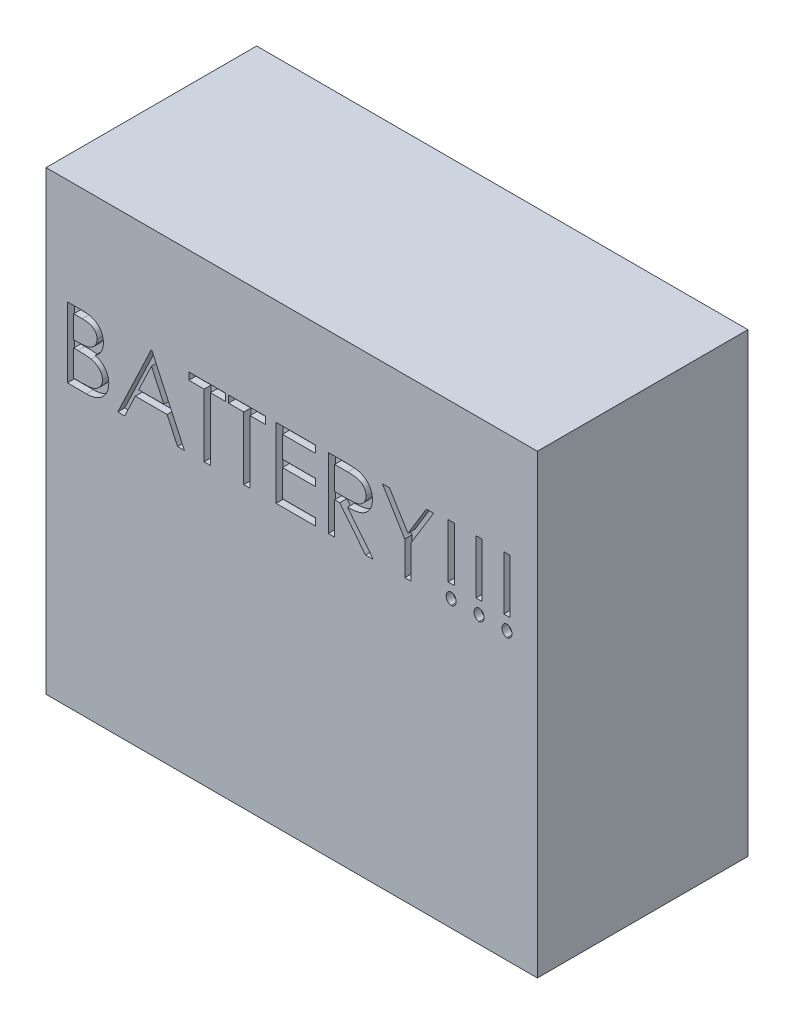
from build123d import *

# Parameters (mm, degrees)
SKETCH1_W           = 177.8
SKETCH1_H           = 76.2
BOSS_EXTRUDE1_DEPTH = 82.55
SKETCH2_W           = 2.279487179
SKETCH2_H           = 19.538461538
SKETCH2_W_2         = 2.27948718
CUT_EXTRUDE1_DEPTH  = 2.54


with BuildPart() as part:
    # Sketch1 → Boss-Extrude1 (new body, symmetric)
    with BuildSketch(Plane(origin=(0, 0, 0), x_dir=(1, 0, 0), z_dir=(0, 1, 0))):
        Rectangle(SKETCH1_W, SKETCH1_H)
    extrude(amount=BOSS_EXTRUDE1_DEPTH, both=True)

    # Sketch2 → Cut-Extrude1 (cut)
    with BuildSketch(Plane.XY.offset(38.1)):
        with BuildLine():
            Line((-81.188057104, 44.331904779), (-76.232207745, 44.331904779))
            add(Edge.make_bspline(
                [(-76.232207745, 44.331904779), (-75.989612503, 44.330629333), (-75.519402548, 44.328157202), (-74.835638599, 44.289816765), (-74.195204373, 44.237538703), (-73.597914139, 44.154588888), (-73.044043899, 44.054499991), (-72.531924474, 43.933292526), (-72.063184367, 43.787956529), (-71.503566223, 43.556843517), (-70.865513427, 43.213412524), (-70.174645091, 42.705930937), (-69.583882897, 42.085209633), (-69.074530766, 41.385021219), (-68.66957407, 40.614778761), (-68.376608312, 39.792840649), (-68.191131159, 38.929808579), (-68.172056237, 38.337312373), (-68.162416078, 38.03787433)],
                knots=[0, 0, 0, 0, 0.000727675, 0.001410416, 0.00205396, 0.002654813, 0.003218679, 0.003741942, 0.004232757, 0.004689132, 0.005556522, 0.006400141, 0.007249358, 0.008116494, 0.00899047, 0.0098499, 0.010728043, 0.011625303, 0.011625303, 0.011625303, 0.011625303], degree=3))
            add(Edge.make_bspline(
                [(-68.162416078, 38.03787433), (-68.17034972, 37.757367212), (-68.185940076, 37.206144271), (-68.335021815, 36.39991845), (-68.56841638, 35.632466747), (-68.89284876, 34.906590007), (-69.314503247, 34.238688929), (-69.814217902, 33.623375627), (-70.417118126, 33.086702242), (-70.86882621, 32.786670892), (-71.09827345, 32.634268561)],
                knots=[0, 0, 0, 0, 0.000840791, 0.001652234, 0.002450537, 0.003243047, 0.004029408, 0.00481379, 0.005613681, 0.006439435, 0.006439435, 0.006439435, 0.006439435], degree=3))
            add(Edge.make_bspline(
                [(-71.09827345, 32.634268561), (-70.809726347, 32.523488283), (-70.25766426, 32.311538169), (-69.497942913, 31.93681223), (-68.843386037, 31.529235772), (-68.288961035, 31.084141774), (-67.814796339, 30.60438069), (-67.400754992, 30.082917861), (-67.047467305, 29.512950875), (-66.74475066, 28.900422361), (-66.508539688, 28.251586848), (-66.331640267, 27.572530359), (-66.230276494, 26.865687872), (-66.215851897, 26.384645405), (-66.208569924, 26.141800612)],
                knots=[0, 0, 0, 0, 0.000926894, 0.001773378, 0.002537091, 0.003235576, 0.003901189, 0.00455677, 0.00522879, 0.005909176, 0.006602975, 0.007296532, 0.008011067, 0.008739542, 0.008739542, 0.008739542, 0.008739542], degree=3))
            add(Edge.make_bspline(
                [(-66.208569924, 26.141800612), (-66.215659035, 25.89384674), (-66.22960706, 25.405990551), (-66.332513141, 24.689310431), (-66.50675066, 24.004417962), (-66.746752694, 23.346883207), (-67.059987777, 22.717978231), (-67.441190718, 22.116990544), (-67.895716923, 21.549958545), (-68.404173172, 21.010581394), (-68.979389885, 20.525602595), (-69.599989935, 20.093688609), (-70.273788942, 19.738480044), (-70.989720556, 19.440095202), (-71.755815878, 19.212168676), (-72.5686348, 19.052710569), (-73.427476305, 18.9452683), (-74.01682707, 18.93643487), (-74.319066719, 18.931904779)],
                knots=[0, 0, 0, 0, 0.000743722, 0.001463294, 0.00216671, 0.002860509, 0.003559087, 0.004270499, 0.004991239, 0.005736213, 0.006490649, 0.007244313, 0.008000052, 0.008771102, 0.009567929, 0.010393165, 0.011254009, 0.012160212, 0.012160212, 0.012160212, 0.012160212], degree=3))
            Line((-74.319066719, 18.931904779), (-81.188057104, 18.931904779))
            Line((-81.188057104, 18.931904779), (-81.188057104, 44.331904779))
        make_face()
        with BuildLine():
            Line((-78.908569924, 41.726776574), (-78.908569924, 33.585750933))
            Line((-78.908569924, 33.585750933), (-77.377039475, 33.585750933))
            add(Edge.make_bspline(
                [(-77.377039475, 33.585750933), (-77.15316536, 33.588653231), (-76.720594948, 33.594261063), (-76.094159127, 33.610324873), (-75.512680423, 33.655304959), (-74.977162549, 33.700272118), (-74.488448813, 33.77338484), (-74.047621932, 33.860413389), (-73.647763543, 33.952455043), (-73.186647984, 34.108987891), (-72.663604301, 34.340328734), (-72.106015488, 34.699352916), (-71.614456766, 35.126975365), (-71.199368603, 35.620395487), (-70.859651074, 36.163710093), (-70.623694399, 36.748250311), (-70.463694108, 37.359447841), (-70.44924128, 37.779043161), (-70.441903257, 37.992081061)],
                knots=[0, 0, 0, 0, 0.000671712, 0.001297884, 0.001879358, 0.002421096, 0.00290969, 0.00336073, 0.00376921, 0.004139283, 0.004820201, 0.005479326, 0.006121199, 0.006767473, 0.007407143, 0.008034555, 0.008652821, 0.009290485, 0.009290485, 0.009290485, 0.009290485], degree=3))
            add(Edge.make_bspline(
                [(-70.441903257, 37.992081061), (-70.445721822, 38.13305666), (-70.453212354, 38.409595692), (-70.514559179, 38.812725291), (-70.618826719, 39.191865666), (-70.752752161, 39.552212638), (-70.939904359, 39.882498637), (-71.16025635, 40.194143543), (-71.426489645, 40.476534346), (-71.729528429, 40.74047299), (-72.077933863, 40.974476135), (-72.471498095, 41.179423388), (-72.915545809, 41.344456453), (-73.402593385, 41.488990817), (-73.940137848, 41.590505863), (-74.521976036, 41.675076162), (-75.152873711, 41.718130918), (-75.589355312, 41.723830409), (-75.81498018, 41.726776574)],
                knots=[0, 0, 0, 0, 0.000422806, 0.00082938, 0.001219412, 0.001601158, 0.001979224, 0.002354817, 0.002743652, 0.003140462, 0.003558186, 0.003999683, 0.004468372, 0.004977186, 0.005522021, 0.006107755, 0.006740344, 0.007417239, 0.007417239, 0.007417239, 0.007417239], degree=3))
            Line((-75.81498018, 41.726776574), (-78.908569924, 41.726776574))
        make_face(mode=Mode.SUBTRACT)
        with BuildLine():
            Line((-78.908569924, 30.980622728), (-78.908569924, 21.537032984))
            Line((-78.908569924, 21.537032984), (-75.66233595, 21.537032984))
            add(Edge.make_bspline(
                [(-75.66233595, 21.537032984), (-75.42997003, 21.539817894), (-74.982115354, 21.54518544), (-74.335494998, 21.562708208), (-73.736177616, 21.602566437), (-73.186898003, 21.665310603), (-72.681725003, 21.733371348), (-72.226718816, 21.824893216), (-71.818191069, 21.929751386), (-71.344486093, 22.091833665), (-70.811060633, 22.343630911), (-70.236216132, 22.723282726), (-69.725123006, 23.175571873), (-69.291107696, 23.699036222), (-68.935413437, 24.268223566), (-68.676656705, 24.871621248), (-68.517065917, 25.499259076), (-68.497746174, 25.927188933), (-68.488057104, 26.141800612)],
                knots=[0, 0, 0, 0, 0.00069715, 0.001343664, 0.001940366, 0.002498325, 0.003002025, 0.003469026, 0.003889868, 0.004266391, 0.004969696, 0.005652721, 0.006326684, 0.007009424, 0.007685764, 0.008333159, 0.008972405, 0.009615526, 0.009615526, 0.009615526, 0.009615526], degree=3))
            add(Edge.make_bspline(
                [(-68.488057104, 26.141800612), (-68.490060832, 26.276009426), (-68.494035969, 26.542262254), (-68.553984432, 26.933537056), (-68.641170801, 27.31254768), (-68.753884636, 27.680323282), (-68.91803734, 28.030214642), (-69.109673409, 28.369141788), (-69.334364724, 28.697552753), (-69.684479528, 29.11275025), (-70.193727644, 29.591119429), (-70.917313957, 30.059477303), (-71.740072919, 30.437195674), (-72.336809582, 30.597574731), (-72.645068322, 30.680422407)],
                knots=[0, 0, 0, 0, 0.000402253, 0.000798017, 0.001184348, 0.001568932, 0.001949183, 0.002341102, 0.002736277, 0.003140841, 0.003968849, 0.00482123, 0.005716063, 0.006672255, 0.006672255, 0.006672255, 0.006672255], degree=3))
            add(Edge.make_bspline(
                [(-72.645068322, 30.680422407), (-72.768650903, 30.705496445), (-73.03660343, 30.759862131), (-73.473538442, 30.817249464), (-73.972364462, 30.86837647), (-74.534233343, 30.906194586), (-75.159855961, 30.945285502), (-75.850568457, 30.960487918), (-76.603550112, 30.978625406), (-77.126009043, 30.979939923), (-77.397392039, 30.980622728)],
                knots=[0, 0, 0, 0, 0.000378203, 0.000820023, 0.00132125, 0.001882424, 0.002509278, 0.003201564, 0.003954764, 0.004768882, 0.004768882, 0.004768882, 0.004768882], degree=3))
            Line((-77.397392039, 30.980622728), (-78.908569924, 30.980622728))
        make_face(mode=Mode.SUBTRACT)
        Polygon((-50.577800693, 44.331904779), (-38.85472377, 18.931904779), (-41.33264845, 18.931904779), (-45.087696527, 27.07293042), (-56.602159668, 27.07293042), (-60.464058706, 18.931904779), (-62.952159668, 18.931904779), (-50.903441719, 44.331904779), align=None)
        Polygon((-50.766061911, 39.381143561), (-55.365741398, 29.678058625), (-46.288497809, 29.678058625), align=None, mode=Mode.SUBTRACT)
        Polygon((-37.226518642, 41.726776574), (-37.226518642, 44.331904779), (-23.875236591, 44.331904779), (-23.875236591, 41.726776574), (-29.411134027, 41.726776574), (-29.411134027, 18.931904779), (-31.690621206, 18.931904779), (-31.690621206, 41.726776574), align=None)
        Polygon((-22.898313514, 41.726776574), (-22.898313514, 44.331904779), (-9.547031463, 44.331904779), (-9.547031463, 41.726776574), (-15.082928898, 41.726776574), (-15.082928898, 18.931904779), (-17.362416078, 18.931904779), (-17.362416078, 41.726776574), align=None)
        Polygon((-5.639339155, 44.331904779), (8.688865973, 44.331904779), (8.688865973, 41.726776574), (-3.359851975, 41.726776574), (-3.359851975, 33.911391959), (8.688865973, 33.911391959), (8.688865973, 31.306263753), (-3.359851975, 31.306263753), (-3.359851975, 21.537032984), (8.688865973, 21.537032984), (8.688865973, 18.931904779), (-5.639339155, 18.931904779), align=None)
        with BuildLine():
            Line((13.247840332, 44.331904779), (18.330893217, 44.331904779))
            add(Edge.make_bspline(
                [(18.330893217, 44.331904779), (18.670100264, 44.330775669), (19.321415369, 44.328607654), (20.25448996, 44.316518974), (21.102320892, 44.281870793), (21.864464869, 44.252054216), (22.540907908, 44.197684127), (23.133724246, 44.145718288), (23.640183537, 44.077692293), (23.946767715, 44.014515795), (24.085580717, 43.985911189)],
                knots=[0, 0, 0, 0, 0.001017641, 0.001953983, 0.002799166, 0.003563218, 0.004241851, 0.004834723, 0.005348499, 0.005773595, 0.005773595, 0.005773595, 0.005773595], degree=3))
            add(Edge.make_bspline(
                [(24.085580717, 43.985911189), (24.271411646, 43.939996949), (24.639109227, 43.849147944), (25.168518278, 43.657126841), (25.672993657, 43.434915851), (26.150439811, 43.173921995), (26.598465267, 42.87220788), (27.02168958, 42.534982077), (27.422033228, 42.164089784), (27.78330563, 41.750179791), (28.123949034, 41.315937692), (28.411249352, 40.846373286), (28.65891009, 40.355343914), (28.856090414, 39.837855797), (29.014861993, 39.29892751), (29.126812416, 38.733677385), (29.193949606, 38.144680594), (29.200784786, 37.742940342), (29.204250589, 37.53923651)],
                knots=[0, 0, 0, 0, 0.000573901, 0.001135559, 0.001686795, 0.002226474, 0.002765553, 0.003305112, 0.003848686, 0.00440011, 0.004951698, 0.005502371, 0.006048487, 0.006599371, 0.007161305, 0.007732085, 0.008326004, 0.00893692, 0.00893692, 0.00893692, 0.00893692], degree=3))
            add(Edge.make_bspline(
                [(29.204250589, 37.53923651), (29.19358986, 37.200798894), (29.172788016, 36.540419447), (28.978840121, 35.582034764), (28.661147663, 34.68803231), (28.223372937, 33.859537737), (27.665883028, 33.112700482), (26.995868829, 32.456724035), (26.212956563, 31.907794384), (25.48412667, 31.527136887), (24.84031505, 31.28334835), (24.310301865, 31.111815917), (23.732147229, 30.979286226), (23.111390572, 30.860558413), (22.445448615, 30.770920402), (21.735917472, 30.705267974), (20.982291114, 30.664235734), (20.464573297, 30.658125185), (20.198240973, 30.654981702)],
                knots=[0, 0, 0, 0, 0.001014379, 0.001979317, 0.002919178, 0.003852405, 0.004779466, 0.005704179, 0.006652923, 0.007638303, 0.008161788, 0.008716955, 0.0093081, 0.009939788, 0.010612597, 0.011322935, 0.01207708, 0.012876064, 0.012876064, 0.012876064, 0.012876064], degree=3))
            Line((20.198240973, 30.654981702), (29.529891614, 18.931904779))
            Line((29.529891614, 18.931904779), (26.711061486, 18.931904779))
            Line((26.711061486, 18.931904779), (17.379410845, 30.654981702))
            Line((17.379410845, 30.654981702), (15.527327512, 30.654981702))
            Line((15.527327512, 30.654981702), (15.527327512, 18.931904779))
            Line((15.527327512, 18.931904779), (13.247840332, 18.931904779))
            Line((13.247840332, 18.931904779), (13.247840332, 44.331904779))
        make_face()
        with BuildLine():
            Line((15.527327512, 41.726776574), (15.527327512, 33.260109907))
            Line((15.527327512, 33.260109907), (20.177888409, 33.22449292))
            add(Edge.make_bspline(
                [(20.177888409, 33.22449292), (20.395022406, 33.22439686), (20.815889935, 33.224210668), (21.424769045, 33.253194072), (21.991697856, 33.286165582), (22.514507886, 33.336597975), (22.993432689, 33.401593467), (23.428232888, 33.482895124), (23.819618236, 33.577615807), (24.276081915, 33.724221892), (24.785798457, 33.956494139), (25.339746766, 34.294426615), (25.811478017, 34.71947108), (26.210024789, 35.205507018), (26.530278378, 35.739895795), (26.756063, 36.316231732), (26.899336724, 36.919965043), (26.916235311, 37.33491474), (26.924763409, 37.544324651)],
                knots=[0, 0, 0, 0, 0.000651302, 0.001262409, 0.001828314, 0.002354857, 0.002837694, 0.003277782, 0.00368132, 0.004044971, 0.004714521, 0.005356877, 0.005983937, 0.006609365, 0.007236776, 0.007844314, 0.008460231, 0.009087746, 0.009087746, 0.009087746, 0.009087746], degree=3))
            add(Edge.make_bspline(
                [(26.924763409, 37.544324651), (26.916039445, 37.748588357), (26.898751731, 38.15336449), (26.757609239, 38.745953096), (26.5189263, 39.305238962), (26.197273488, 39.828946939), (25.805393906, 40.304331422), (25.345887494, 40.711073619), (24.831318363, 41.046712591), (24.350378809, 41.261192952), (23.920507667, 41.392691316), (23.547275277, 41.485228333), (23.125551982, 41.559573908), (22.653290082, 41.619140978), (22.132505676, 41.670339716), (21.560565522, 41.704824053), (20.941264317, 41.725244667), (20.512026588, 41.726254055), (20.289827512, 41.726776574)],
                knots=[0, 0, 0, 0, 0.000612292, 0.001213339, 0.001815311, 0.00242965, 0.003051154, 0.003656664, 0.004263519, 0.0048876, 0.005228771, 0.005611331, 0.006040487, 0.006512562, 0.007039104, 0.007610088, 0.008231175, 0.008897741, 0.008897741, 0.008897741, 0.008897741], degree=3))
            Line((20.289827512, 41.726776574), (15.527327512, 41.726776574))
        make_face(mode=Mode.SUBTRACT)
        Polygon((32.786301871, 44.331904779), (35.396518217, 44.331904779), (42.072159243, 33.417842279), (48.737623986, 44.331904779), (51.347840332, 44.331904779), (43.206814691, 31.006063433), (43.206814691, 18.931904779), (40.927327512, 18.931904779), (40.927327512, 31.006063433), align=None)
        with Locations((57.697840333, 35.213956061)):
            Rectangle(SKETCH2_W, SKETCH2_H)
        with BuildLine():
            add(Edge.make_bspline(
                [(57.697840332, 22.839597087), (57.817420195, 22.831213966), (58.053468029, 22.814665883), (58.394929065, 22.698099903), (58.704688791, 22.498974275), (58.976073081, 22.227741661), (59.203858801, 21.906437516), (59.367878414, 21.541740316), (59.47567112, 21.144612099), (59.484385056, 20.866131772), (59.488865973, 20.72293042)],
                knots=[0, 0, 0, 0, 0.000358488, 0.000707648, 0.001069013, 0.001454001, 0.001852081, 0.002243702, 0.002648489, 0.003076982, 0.003076982, 0.003076982, 0.003076982], degree=3))
            add(Edge.make_bspline(
                [(59.488865973, 20.72293042), (59.484102356, 20.583165622), (59.474729481, 20.308164922), (59.368123867, 19.914135332), (59.202372668, 19.548927457), (58.977795142, 19.223799168), (58.704670866, 18.951607305), (58.393908, 18.754234049), (58.054547925, 18.629705193), (57.817596359, 18.614133655), (57.697840332, 18.606263753)],
                knots=[0, 0, 0, 0, 0.000418343, 0.00082313, 0.001214752, 0.001617005, 0.002001992, 0.002363358, 0.002714181, 0.00307267, 0.00307267, 0.00307267, 0.00307267], degree=3))
            add(Edge.make_bspline(
                [(57.697840332, 18.606263753), (57.578084305, 18.614133655), (57.341132739, 18.629705193), (57.001772664, 18.754234049), (56.691009799, 18.951607305), (56.417885522, 19.223799168), (56.193307996, 19.548927457), (56.027556798, 19.914135332), (55.920951183, 20.308164922), (55.911578308, 20.583165622), (55.906814691, 20.72293042)],
                knots=[0, 0, 0, 0, 0.000358488, 0.000709312, 0.001070677, 0.001455665, 0.001857918, 0.00224954, 0.002654327, 0.00307267, 0.00307267, 0.00307267, 0.00307267], degree=3))
            add(Edge.make_bspline(
                [(55.906814691, 20.72293042), (55.911295609, 20.866131772), (55.920009545, 21.144612099), (56.027802251, 21.541740316), (56.191821863, 21.906437516), (56.419607583, 22.227741661), (56.690991873, 22.498974275), (57.000751599, 22.698099903), (57.342212636, 22.814665883), (57.57826047, 22.831213966), (57.697840332, 22.839597087)],
                knots=[0, 0, 0, 0, 0.000428493, 0.00083328, 0.001224902, 0.001622981, 0.002007969, 0.002369335, 0.002718494, 0.003076982, 0.003076982, 0.003076982, 0.003076982], degree=3))
        make_face()
        with Locations((67.792712127, 35.213956061)):
            Rectangle(SKETCH2_W_2, SKETCH2_H)
        with BuildLine():
            add(Edge.make_bspline(
                [(67.792712127, 22.839597087), (67.91229199, 22.831213966), (68.148339824, 22.814665883), (68.48980086, 22.698099903), (68.799560586, 22.498974275), (69.070944876, 22.227741661), (69.298730596, 21.906437516), (69.462750209, 21.541740316), (69.570542914, 21.144612099), (69.579256851, 20.866131772), (69.583737768, 20.72293042)],
                knots=[0, 0, 0, 0, 0.000358488, 0.000707648, 0.001069013, 0.001454001, 0.001852081, 0.002243702, 0.002648489, 0.003076982, 0.003076982, 0.003076982, 0.003076982], degree=3))
            add(Edge.make_bspline(
                [(69.583737768, 20.72293042), (69.578974151, 20.583165622), (69.569601276, 20.308164922), (69.462995662, 19.914135332), (69.297244463, 19.548927457), (69.072666937, 19.223799168), (68.79954266, 18.951607305), (68.488779795, 18.754234049), (68.14941972, 18.629705193), (67.912468154, 18.614133655), (67.792712127, 18.606263753)],
                knots=[0, 0, 0, 0, 0.000418343, 0.00082313, 0.001214752, 0.001617005, 0.002001992, 0.002363358, 0.002714181, 0.00307267, 0.00307267, 0.00307267, 0.00307267], degree=3))
            add(Edge.make_bspline(
                [(67.792712127, 18.606263753), (67.6729561, 18.614133655), (67.436004534, 18.629705193), (67.096644459, 18.754234049), (66.785881594, 18.951607305), (66.512757317, 19.223799168), (66.288179791, 19.548927457), (66.122428592, 19.914135332), (66.015822978, 20.308164922), (66.006450103, 20.583165622), (66.001686486, 20.72293042)],
                knots=[0, 0, 0, 0, 0.000358488, 0.000709312, 0.001070677, 0.001455665, 0.001857918, 0.00224954, 0.002654327, 0.00307267, 0.00307267, 0.00307267, 0.00307267], degree=3))
            add(Edge.make_bspline(
                [(66.001686486, 20.72293042), (66.006167404, 20.866131772), (66.01488134, 21.144612099), (66.122674045, 21.541740316), (66.286693658, 21.906437516), (66.514479378, 22.227741661), (66.785863668, 22.498974275), (67.095623394, 22.698099903), (67.437084431, 22.814665883), (67.673132264, 22.831213966), (67.792712127, 22.839597087)],
                knots=[0, 0, 0, 0, 0.000428493, 0.00083328, 0.001224902, 0.001622981, 0.002007969, 0.002369335, 0.002718494, 0.003076982, 0.003076982, 0.003076982, 0.003076982], degree=3))
        make_face()
        with Locations((77.887583922, 35.213956061)):
            Rectangle(SKETCH2_W_2, SKETCH2_H)
        with BuildLine():
            add(Edge.make_bspline(
                [(77.887583922, 22.839597087), (78.007163785, 22.831213966), (78.243211619, 22.814665883), (78.584672655, 22.698099903), (78.894432381, 22.498974275), (79.165816671, 22.227741661), (79.393602391, 21.906437516), (79.557622004, 21.541740316), (79.665414709, 21.144612099), (79.674128645, 20.866131772), (79.678609563, 20.72293042)],
                knots=[0, 0, 0, 0, 0.000358488, 0.000707648, 0.001069013, 0.001454001, 0.001852081, 0.002243702, 0.002648489, 0.003076982, 0.003076982, 0.003076982, 0.003076982], degree=3))
            add(Edge.make_bspline(
                [(79.678609563, 20.72293042), (79.673845946, 20.583165622), (79.664473071, 20.308164922), (79.557867457, 19.914135332), (79.392116258, 19.548927457), (79.167538732, 19.223799168), (78.894414455, 18.951607305), (78.58365159, 18.754234049), (78.244291515, 18.629705193), (78.007339949, 18.614133655), (77.887583922, 18.606263753)],
                knots=[0, 0, 0, 0, 0.000418343, 0.00082313, 0.001214752, 0.001617005, 0.002001992, 0.002363358, 0.002714181, 0.00307267, 0.00307267, 0.00307267, 0.00307267], degree=3))
            add(Edge.make_bspline(
                [(77.887583922, 18.606263753), (77.767827895, 18.614133655), (77.530876329, 18.629705193), (77.191516254, 18.754234049), (76.880753389, 18.951607305), (76.607629112, 19.223799168), (76.383051586, 19.548927457), (76.217300387, 19.914135332), (76.110694773, 20.308164922), (76.101321898, 20.583165622), (76.096558281, 20.72293042)],
                knots=[0, 0, 0, 0, 0.000358488, 0.000709312, 0.001070677, 0.001455665, 0.001857918, 0.00224954, 0.002654327, 0.00307267, 0.00307267, 0.00307267, 0.00307267], degree=3))
            add(Edge.make_bspline(
                [(76.096558281, 20.72293042), (76.101039199, 20.866131772), (76.109753135, 21.144612099), (76.21754584, 21.541740316), (76.381565453, 21.906437516), (76.609351173, 22.227741661), (76.880735463, 22.498974275), (77.190495189, 22.698099903), (77.531956225, 22.814665883), (77.768004059, 22.831213966), (77.887583922, 22.839597087)],
                knots=[0, 0, 0, 0, 0.000428493, 0.00083328, 0.001224902, 0.001622981, 0.002007969, 0.002369335, 0.002718494, 0.003076982, 0.003076982, 0.003076982, 0.003076982], degree=3))
        make_face()
    extrude(amount=-CUT_EXTRUDE1_DEPTH, mode=Mode.SUBTRACT)


solid = part.part
